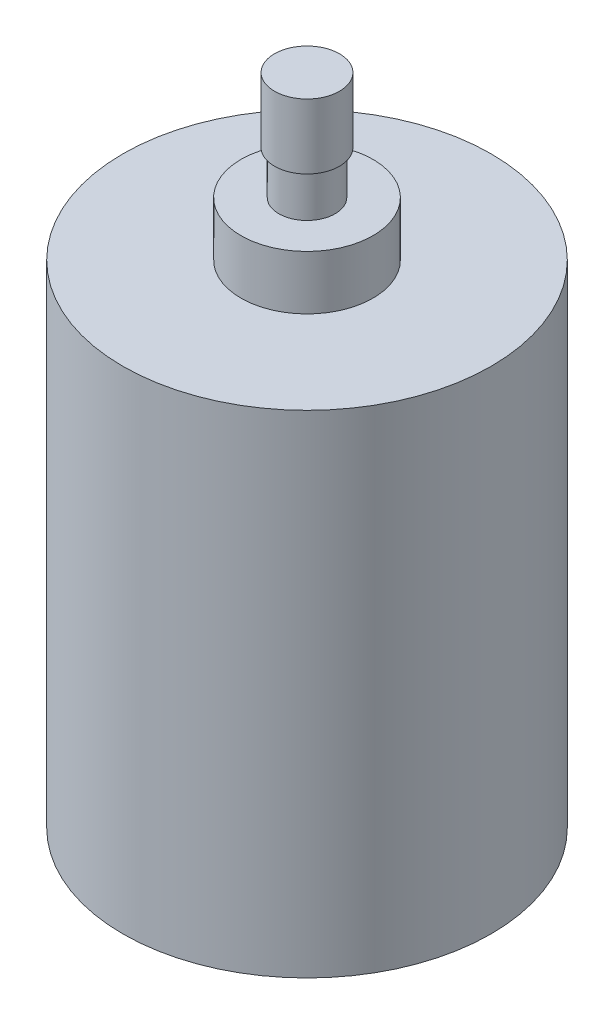
from build123d import *


with BuildPart() as part:
    # Sketch2 → Revolve1 (revolve)
    with BuildSketch(Plane.XY):
        Polygon((-2.3, 0), (-8.5, 0), (-8.5, 22.7), (-3.05, 22.7), (-3.05, 25.2), (-1.3, 25.2), (-1.3, 27.2), (-1.5, 27.2), (-1.5, 30.2), (0, 30.2), (0, -2.5), (-2.3, -2.5), align=None)
    revolve(axis=Axis((0, 30.2, 0), (0, -1, 0)))


solid = part.part
